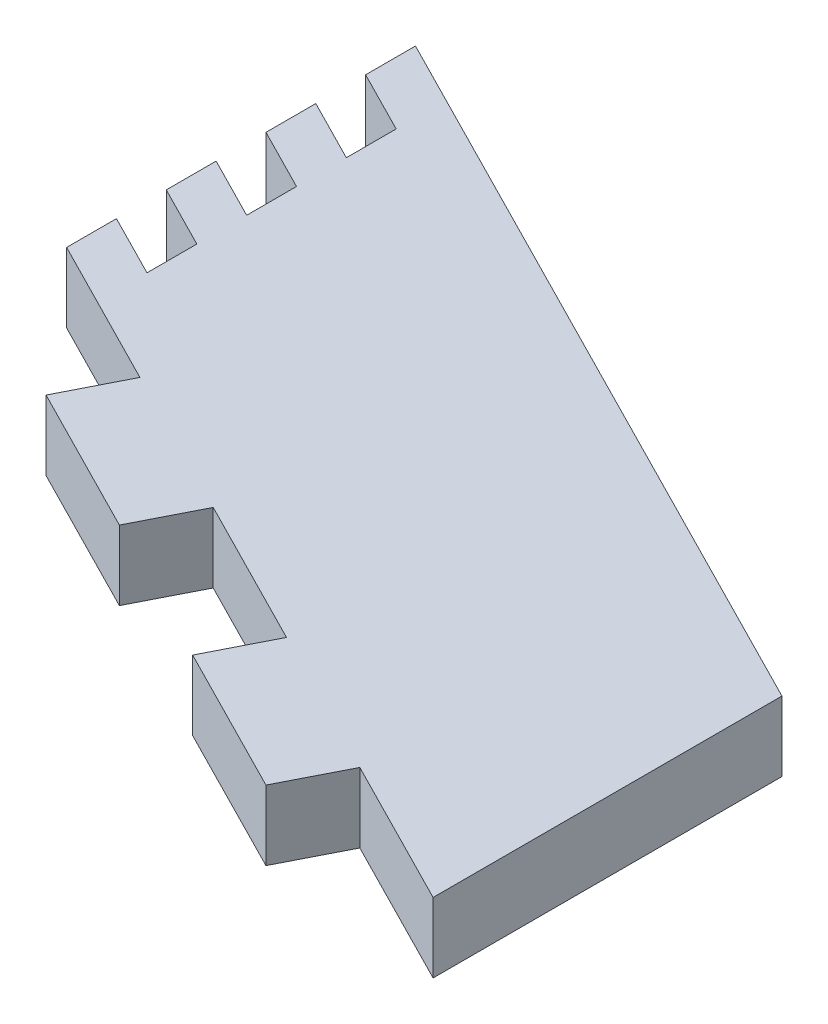
from build123d import *

# Parameters (mm, degrees)
BOSS_EXTRUDE1_DEPTH = 3
BOSS_EXTRUDE2_DEPTH = 3
CUT_EXTRUDE1_DEPTH  = 4


with BuildPart() as part:
    # Sketch1 → Boss-Extrude1 (new body)
    with BuildSketch(Plane(origin=(0, 0, 0), x_dir=(1, 0, 0), z_dir=(0, 1, 0))):
        Polygon((0, 0), (0, 15), (32.084787993, -1.326860674), (32.084787993, -16.326860674), align=None)
    extrude(amount=BOSS_EXTRUDE1_DEPTH)

    # Sketch2 → Boss-Extrude2 (add)
    with BuildSketch(Plane(origin=(0, 3, 0), x_dir=(1, 0, 0), z_dir=(0, 1, 0))):
        Polygon((25.667830391, -13.061488537), (24.306761694, -15.735988526), (17.889804096, -12.470616391), (19.250872792, -9.796116403), align=None)
        Polygon((12.833915194, -6.530744268), (11.472846497, -9.205244257), (5.055888898, -5.939872122), (6.416957595, -3.265372133), align=None)
    extrude(amount=-BOSS_EXTRUDE2_DEPTH)

    # Sketch3 → Cut-Extrude1 (cut, through all)
    with BuildSketch(Plane(origin=(0, 3, 0), x_dir=(1, 0, 0), z_dir=(0, 1, 0))):
        Polygon((2.673732333, 0.782286134), (2.673732333, 2.925143134), (0, 4.285714857), (0, 2.142857857), align=None)
        Polygon((2.673732333, 5.068000134), (0, 6.428571857), (0, 8.571428857), (2.673732333, 7.210857134), align=None)
        Polygon((2.673732333, 9.353714134), (0, 10.714285857), (0, 12.857142857), (2.673732333, 11.496571134), align=None)
    extrude(amount=-CUT_EXTRUDE1_DEPTH, mode=Mode.SUBTRACT)


solid = part.part
